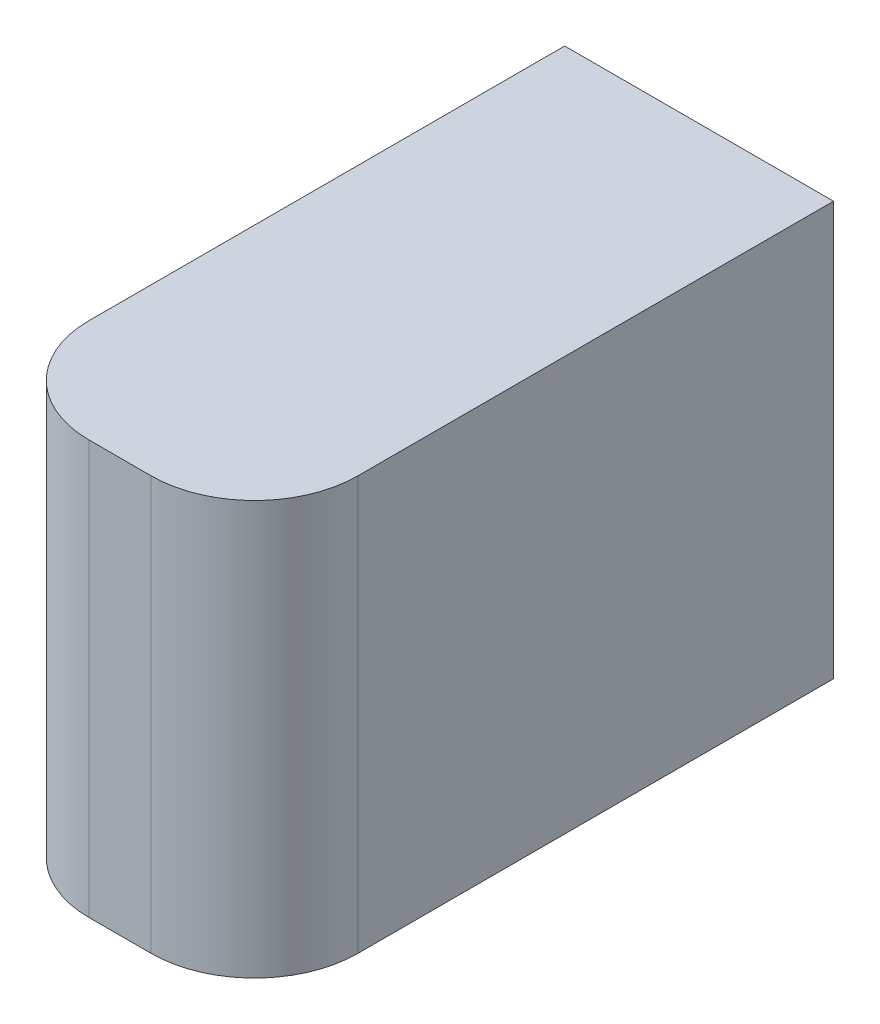
from build123d import *

# Parameters (mm, degrees)
SKETCH1_W      = 2.6
SKETCH1_H      = 4
EXTRUDE1_DEPTH = 5.6
FILLET2_R      = 1


with BuildPart() as part:
    # Sketch1 → Extrude1 (new body)
    with BuildSketch(Plane.XY):
        Rectangle(SKETCH1_W, SKETCH1_H)
    extrude(amount=EXTRUDE1_DEPTH)

    # Fillet2
    fillet2_edges = [part.edges().sort_by_distance(p)[0] for p in [
        (1.3, 0, 5.6),
        (-1.3, 0, 5.6),
    ]]
    fillet(fillet2_edges, radius=FILLET2_R)


solid = part.part
